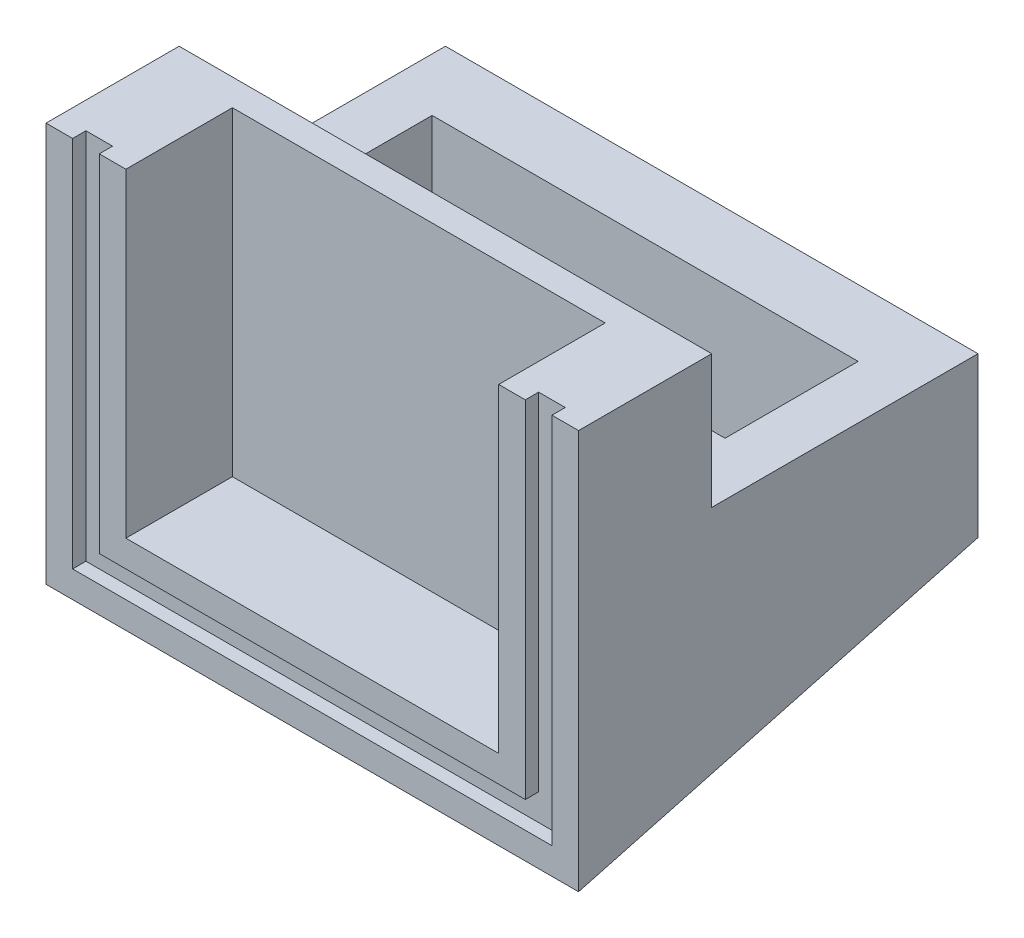
from build123d import *

# Parameters (mm, degrees)
SKETCH1_W           = 20
SKETCH1_H           = 10
BOSS_EXTRUDE1_DEPTH = 10
SKETCH2_W           = 16
SKETCH2_H           = 5
CUT_EXTRUDE1_DEPTH  = 11
SKETCH3_W           = 20
SKETCH3_H           = 15
BOSS_EXTRUDE2_DEPTH = 5
SKETCH4_W           = 14
SKETCH4_H           = 12
CUT_EXTRUDE2_DEPTH  = 4
CUT_EXTRUDE3_DEPTH  = 0.5
CUT_EXTRUDE4_DEPTH  = 21


with BuildPart() as part:
    # Sketch1 → Boss-Extrude1 (new body)
    with BuildSketch(Plane(origin=(0, 0, 0), x_dir=(1, 0, 0), z_dir=(0, 1, 0))):
        Rectangle(SKETCH1_W, SKETCH1_H)
    extrude(amount=BOSS_EXTRUDE1_DEPTH)

    # Sketch2 → Cut-Extrude1 (cut, through all)
    with BuildSketch(Plane(origin=(0, 10, 0), x_dir=(1, 0, 0), z_dir=(0, 1, 0))):
        Rectangle(SKETCH2_W, SKETCH2_H)
    extrude(amount=-CUT_EXTRUDE1_DEPTH, mode=Mode.SUBTRACT)

    # Sketch3 → Boss-Extrude2 (add)
    with BuildSketch(Plane.XY.offset(5)):
        with Locations((0, 7.5)):
            Rectangle(SKETCH3_W, SKETCH3_H)
    extrude(amount=BOSS_EXTRUDE2_DEPTH)

    # Sketch4 → Cut-Extrude2 (cut)
    with BuildSketch(Plane.XY.offset(10)):
        with Locations((0, 9)):
            Rectangle(SKETCH4_W, SKETCH4_H)
    extrude(amount=-CUT_EXTRUDE2_DEPTH, mode=Mode.SUBTRACT)

    # Sketch5 → Cut-Extrude3 (cut)
    with BuildSketch(Plane.XY.offset(10)):
        Polygon((-9, 15), (-9, 1), (0, 1), (9, 1), (9, 15), (8, 15), (8, 2), (0, 2), (-8, 2), (-8, 15), align=None)
    extrude(amount=-CUT_EXTRUDE3_DEPTH, mode=Mode.SUBTRACT)

    # Sketch7 → Cut-Extrude4 (cut, through all)
    with BuildSketch(Plane(origin=(10, 0, 0), x_dir=(0, 0, -1), z_dir=(1, 0, 0))):
        Polygon((5, 4.019237886), (-10, 0), (5, 0), align=None)
    extrude(amount=-CUT_EXTRUDE4_DEPTH, mode=Mode.SUBTRACT)


solid = part.part
